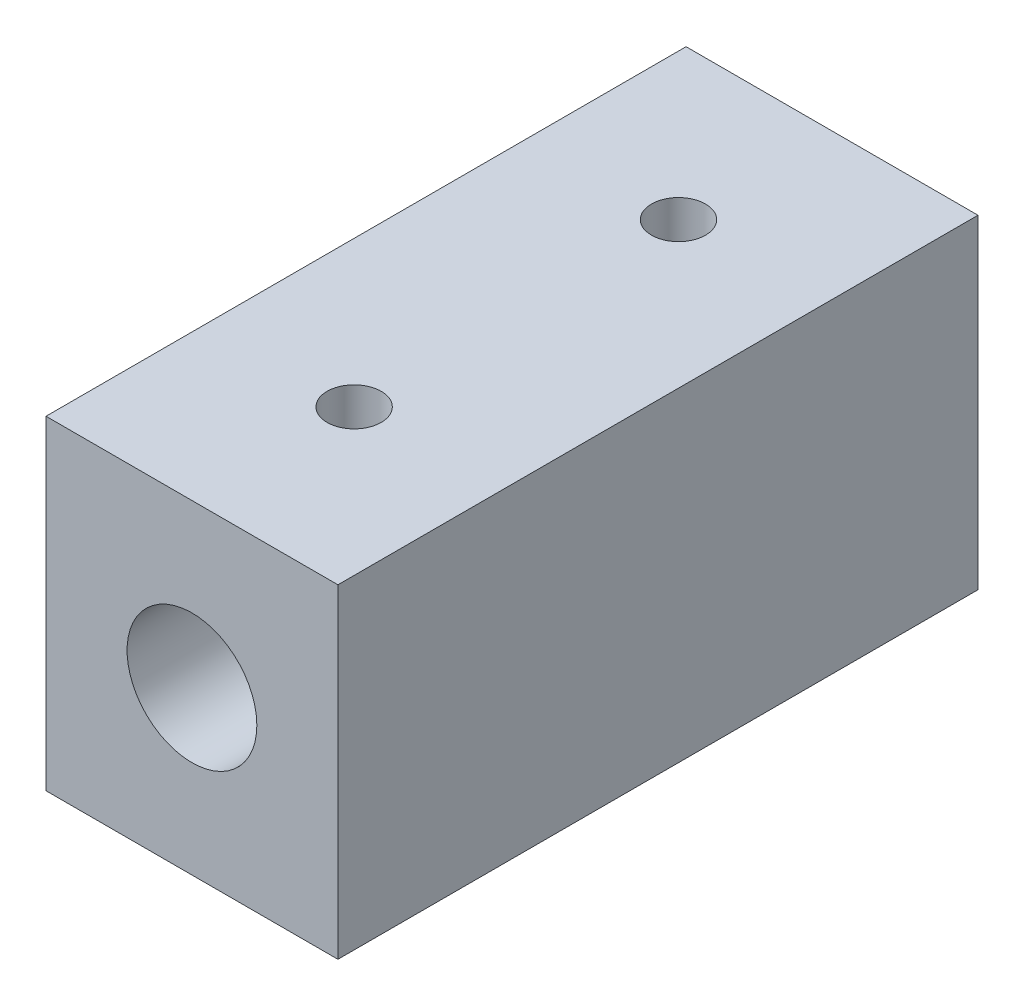
from build123d import *

# Parameters (mm, degrees)
SKETCH1_W                 = 13.5
SKETCH1_H                 = 15
BOSS_EXTRUDE1_DEPTH       = 14.8
SKETCH2_R                 = 3
CUT_EXTRUDE1_DEPTH        = 28.8
SKETCH3_R                 = 1.5
CUT_EXTRUDE2_DEPTH        = 30.6
M3X0_5_TAPPED_HOLE1_D     = 2.5
M3X0_5_TAPPED_HOLE1_DEPTH = 2.7
M3X0_5_TAPPED_HOLE1_TIP   = 0.751075774


with BuildPart() as part:
    # Sketch1 → Boss-Extrude1 (new body, symmetric)
    with BuildSketch(Plane.XY):
        Rectangle(SKETCH1_W, SKETCH1_H)
    extrude(amount=BOSS_EXTRUDE1_DEPTH, both=True)

    # Sketch2 → Cut-Extrude1 (cut)
    with BuildSketch(Plane.XY.offset(14.8)):
        Circle(SKETCH2_R)
    extrude(amount=-CUT_EXTRUDE1_DEPTH, mode=Mode.SUBTRACT)

    # Sketch3 → Cut-Extrude2 (cut, through all)
    with BuildSketch(Plane.XY.offset(14.8)):
        Circle(SKETCH3_R)
    extrude(amount=-CUT_EXTRUDE2_DEPTH, mode=Mode.SUBTRACT)

    # M3x0.5 Tapped Hole1
    with Locations(Plane(origin=(0, 7.5, 0), x_dir=(1, 0, 0), z_dir=(0, 1, 0))):
        with Locations((0, 7.7), (0, -7.3)):
            Hole(M3X0_5_TAPPED_HOLE1_D / 2, depth=M3X0_5_TAPPED_HOLE1_DEPTH)
            with Locations((0, 0, -(M3X0_5_TAPPED_HOLE1_DEPTH + M3X0_5_TAPPED_HOLE1_TIP / 2))):  # 118° drill point
                Cone(0, M3X0_5_TAPPED_HOLE1_D / 2, M3X0_5_TAPPED_HOLE1_TIP, mode=Mode.SUBTRACT)


solid = part.part
